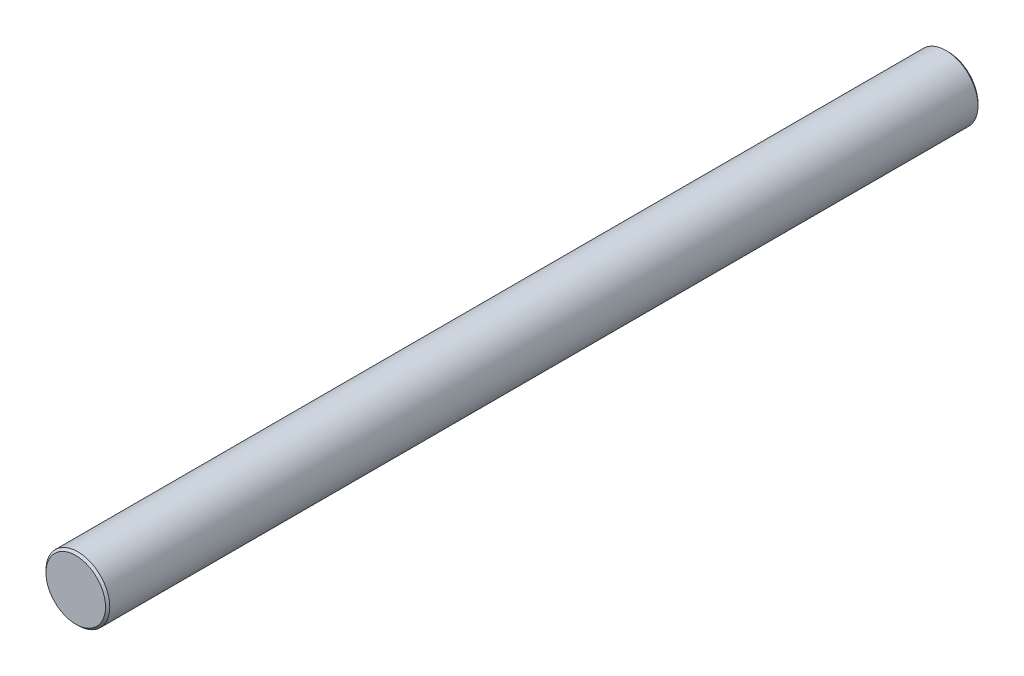
from build123d import *

# Parameters (mm, degrees)
SKETCH1_R           = 3
BOSS_EXTRUDE1_DEPTH = 82
CHAMFER1_SIZE       = 0.2


with BuildPart() as part:
    # Sketch1 → Boss-Extrude1 (new body)
    with BuildSketch(Plane.XY):
        Circle(SKETCH1_R)
    extrude(amount=BOSS_EXTRUDE1_DEPTH)

    # Chamfer1
    chamfer1_edges = [part.edges().sort_by_distance(p)[0] for p in [
        (-3, 0, 0),
        (-3, 0, 82),
    ]]
    chamfer(chamfer1_edges, length=CHAMFER1_SIZE)


solid = part.part
